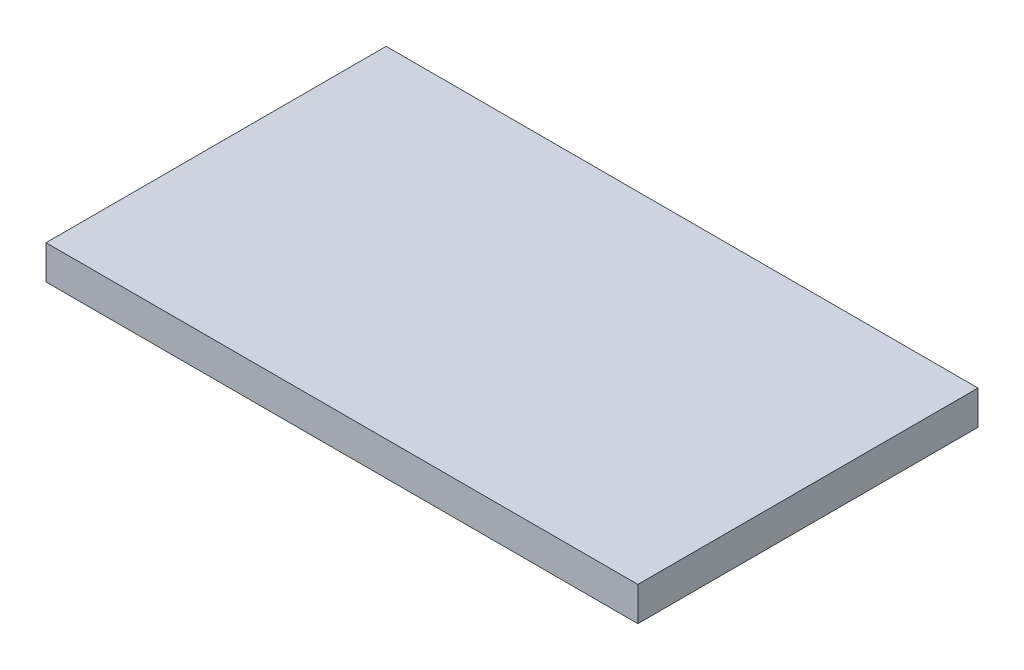
from build123d import *

# Parameters (mm, degrees)
SKETCH1_W           = 87
SKETCH1_H           = 50
BOSS_EXTRUDE1_DEPTH = 5


with BuildPart() as part:
    # Sketch1 → Boss-Extrude1 (new body)
    with BuildSketch(Plane(origin=(0, 0, 0), x_dir=(1, 0, 0), z_dir=(0, 1, 0))):
        Rectangle(SKETCH1_W, SKETCH1_H)
    extrude(amount=BOSS_EXTRUDE1_DEPTH)


solid = part.part
